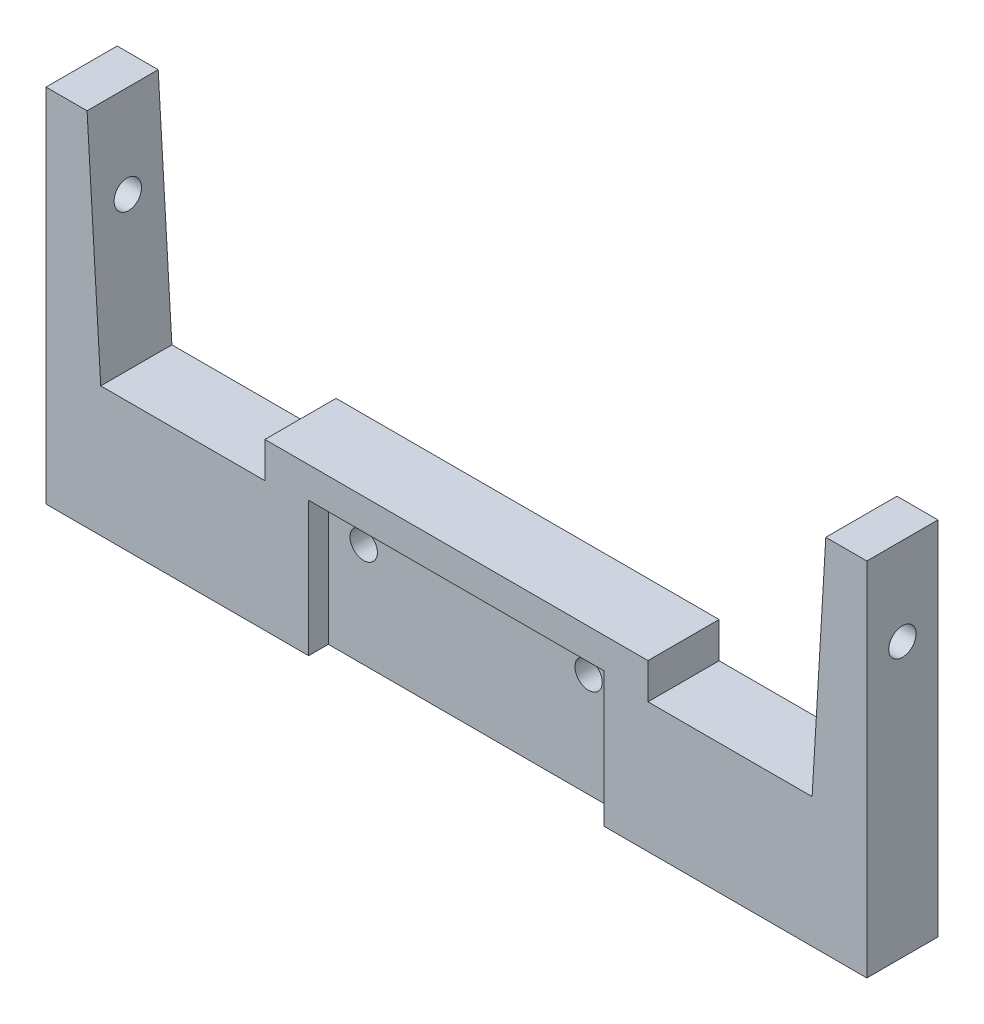
from build123d import *

# Parameters (mm, degrees)
ESTRUSIONE_ESTRUSIONE1_DEPTH = 6.5
TAGLIO_ESTRUSIONE2_DEPTH     = 2.5
SCHIZZO2_R                   = 1.25
TAGLIO_ESTRUSIONE3_DEPTH     = 7.5
SCHIZZO4_W                   = 27
SCHIZZO4_H                   = 12.3
TAGLIO_ESTRUSIONE4_DEPTH     = 1.8
SCHIZZO6_R                   = 1.25
TAGLIO_ESTRUSIONE5_DEPTH     = 76


with BuildPart() as part:
    # Schizzo1 → Estrusione-Estrusione1 (new body)
    with BuildSketch(Plane.XY):
        Polygon((0, 0), (75, 0), (75, 33), (71.25, 33), (70, 11.85394892), (55, 11.85394892), (55, 15.118104456), (20, 15.118104456), (20, 11.85394892), (5, 11.85394892), (3.75, 33), (0, 33), align=None)
    extrude(amount=ESTRUSIONE_ESTRUSIONE1_DEPTH)

    # Schizzo3 → Taglio-Estrusione2 (cut)
    with BuildSketch(Plane(origin=(0, 0, 0), x_dir=(-1, 0, 0), z_dir=(0, 0, -1))):
        Polygon((-44.599573519, 9.5), (-46.18728676, 12.25), (-49.36271324, 12.25), (-50.950426481, 9.5), (-49.36271324, 6.75), (-46.18728676, 6.75), align=None)
        Polygon((-24.049573519, 9.5), (-25.63728676, 12.25), (-28.81271324, 12.25), (-30.400426481, 9.5), (-28.81271324, 6.75), (-25.63728676, 6.75), align=None)
    extrude(amount=-TAGLIO_ESTRUSIONE2_DEPTH, mode=Mode.SUBTRACT)

    # Schizzo2 → Taglio-Estrusione3 (cut, through all)
    with BuildSketch(Plane.XY.offset(6.5)):
        with Locations((27.225, 9.5)):
            Circle(SCHIZZO2_R)
        with Locations((47.775, 9.5)):
            Circle(SCHIZZO2_R)
    extrude(amount=-TAGLIO_ESTRUSIONE3_DEPTH, mode=Mode.SUBTRACT)

    # Schizzo4 → Taglio-Estrusione4 (cut)
    with BuildSketch(Plane.XY.offset(6.5)):
        with Locations((37.496683744, 6.15)):
            Rectangle(SCHIZZO4_W, SCHIZZO4_H)
    extrude(amount=-TAGLIO_ESTRUSIONE4_DEPTH, mode=Mode.SUBTRACT)

    # Schizzo6 → Taglio-Estrusione5 (cut, through all)
    with BuildSketch(Plane.ZY):
        with Locations((3.25, 25)):
            Circle(SCHIZZO6_R)
    extrude(amount=-TAGLIO_ESTRUSIONE5_DEPTH, mode=Mode.SUBTRACT)


solid = part.part
